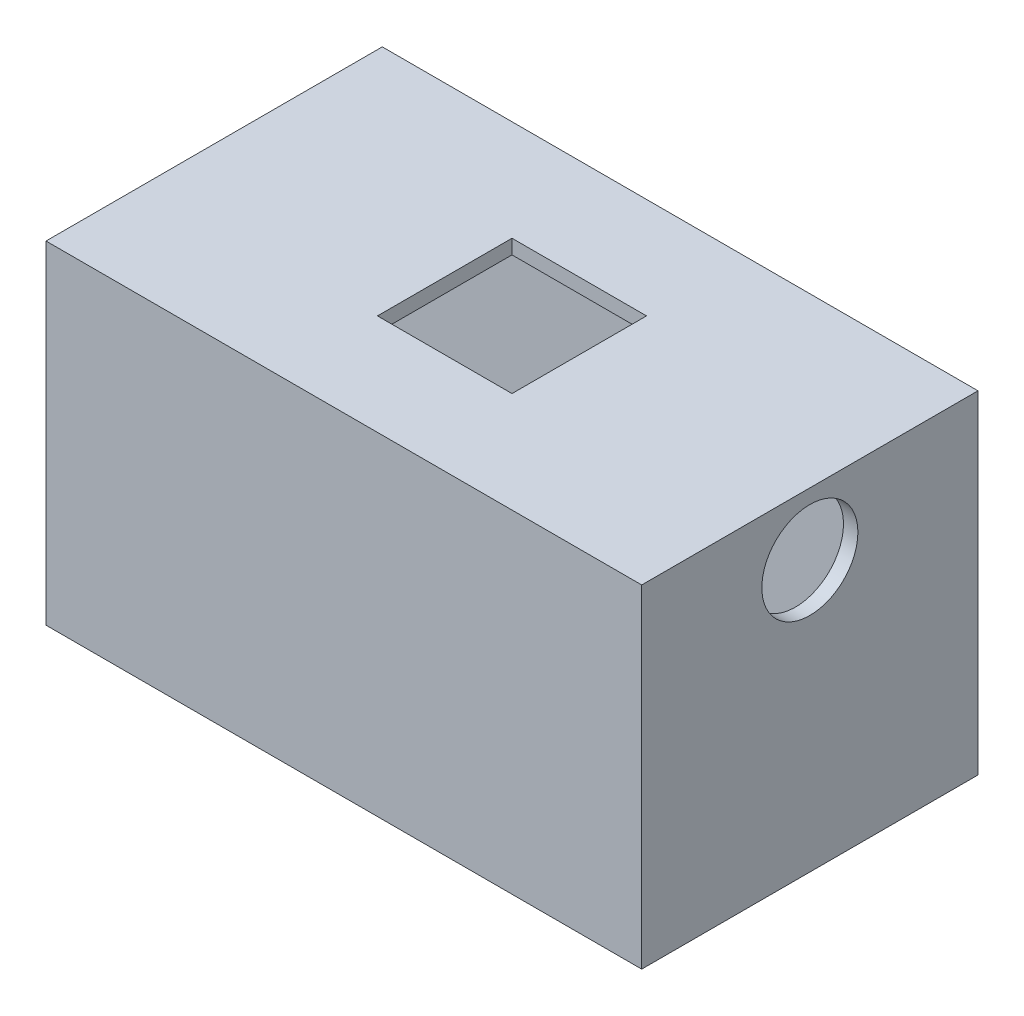
from build123d import *

# Parameters (mm, degrees)
SKETCH_1_W          = 62
SKETCH_1_H          = 35
EXTRUDE_1_DEPTH     = 1.5
SKETCH_2_W          = 62
SKETCH_2_H          = 35
EXTRUDE_2_DEPTH     = 30.629158
SKETCH_3_W          = 59
SKETCH_3_H          = 32
CUT_EXTRUDE_1_DEPTH = 41
SKETCH_4_W          = 62
SKETCH_4_H          = 35
SKETCH_4_W_2        = 59
SKETCH_4_H_2        = 32
EXTRUDE_3_DEPTH     = 1
SKETCH_5_W          = 62
SKETCH_5_H          = 35
EXTRUDE_4_DEPTH     = 1.5
SKETCH_8_R          = 5
CUT_EXTRUDE_3_DEPTH = 1.5
CUT_EXTRUDE_4_REACH = 36.629
SKETCH_10_W         = 14
SKETCH_10_H         = 14


with BuildPart() as part:
    # 草图1 → 凸台-拉伸1 (new body)
    with BuildSketch(Plane(origin=(0, 0, 0), x_dir=(1, 0, 0), z_dir=(0, 1, 0))):
        with Locations((2.996831225, 4.751847291)):
            Rectangle(SKETCH_1_W, SKETCH_1_H)
    extrude(amount=EXTRUDE_1_DEPTH)

    # 草图2 → 凸台-拉伸2 (add)
    with BuildSketch(Plane.XZ):
        with Locations((2.996831225, -4.751847291)):
            Rectangle(SKETCH_2_W, SKETCH_2_H)
    extrude(amount=EXTRUDE_2_DEPTH)

    # 草图3 → 切除-拉伸1 (cut)
    with BuildSketch(Plane.XZ.offset(30.629158461)):
        with Locations((2.996831225, -4.751847291)):
            Rectangle(SKETCH_3_W, SKETCH_3_H)
    extrude(amount=-CUT_EXTRUDE_1_DEPTH, mode=Mode.SUBTRACT)

    # 草图4 → 凸台-拉伸3 (add)
    with BuildSketch(Plane(origin=(0, 1.5, 0), x_dir=(1, 0, 0), z_dir=(0, 1, 0))):
        with Locations((2.996831225, 4.751847291)):
            Rectangle(SKETCH_4_W, SKETCH_4_H)
        with Locations((2.996831225, 4.751847291)):
            Rectangle(SKETCH_4_W_2, SKETCH_4_H_2, mode=Mode.SUBTRACT)
    extrude(amount=EXTRUDE_3_DEPTH)

    # 草图5 → 凸台-拉伸4 (add)
    with BuildSketch(Plane(origin=(0, 2.5, 0), x_dir=(1, 0, 0), z_dir=(0, 1, 0))):
        with Locations((2.996831225, 4.751847291)):
            Rectangle(SKETCH_5_W, SKETCH_5_H)
    extrude(amount=EXTRUDE_4_DEPTH)

    # 草图8 → 切除-拉伸3 (cut)
    with BuildSketch(Plane(origin=(33.996831225, 0, 0), x_dir=(0, 0, -1), z_dir=(1, 0, 0))):
        with Locations((4.751847291, -2.5)):
            Circle(SKETCH_8_R)
    extrude(amount=-CUT_EXTRUDE_3_DEPTH, mode=Mode.SUBTRACT)

    # 草图10 → 切除-拉伸4 (cut, up to next)
    with BuildSketch(Plane(origin=(0, 4, 0), x_dir=(1, 0, 0), z_dir=(0, 1, 0)), mode=Mode.PRIVATE) as cut_extrude_4_sk1:
        with Locations((2.996831225, 4.751847291)):
            Rectangle(SKETCH_10_W, SKETCH_10_H)
    cut_extrude_4_tool1 = extrude(cut_extrude_4_sk1.sketch, amount=-CUT_EXTRUDE_4_REACH, mode=Mode.PRIVATE) & part.part
    add(cut_extrude_4_tool1.solids().sort_by_distance((2.996831, 4, -4.751847))[0], mode=Mode.SUBTRACT)


solid = part.part
